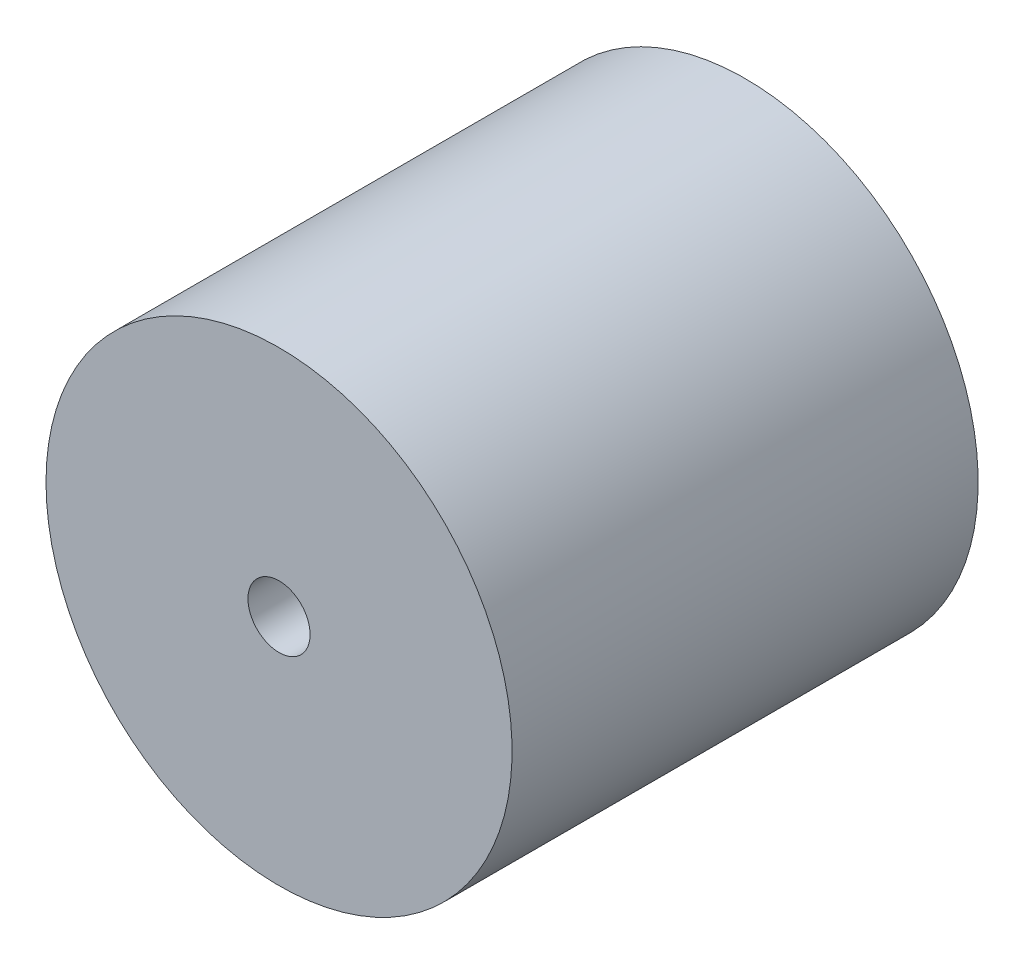
from build123d import *

# Parameters (mm, degrees)
ESQUISSE1_W = 6.5
ESQUISSE1_H = 15


with BuildPart() as part:
    # Esquisse1 → Révolution1 (revolve)
    with BuildSketch(Plane.XZ, mode=Mode.PRIVATE) as r_volution1_sk:
        with Locations((4.25, 7.5)):
            Rectangle(ESQUISSE1_W, ESQUISSE1_H)
    revolve(r_volution1_sk.sketch.rotate(Axis((0, 0, 15), (0, 0, -1)), 180), axis=Axis((0, 0, 15), (0, 0, -1)))  # turned: the seam where the file's is


solid = part.part
